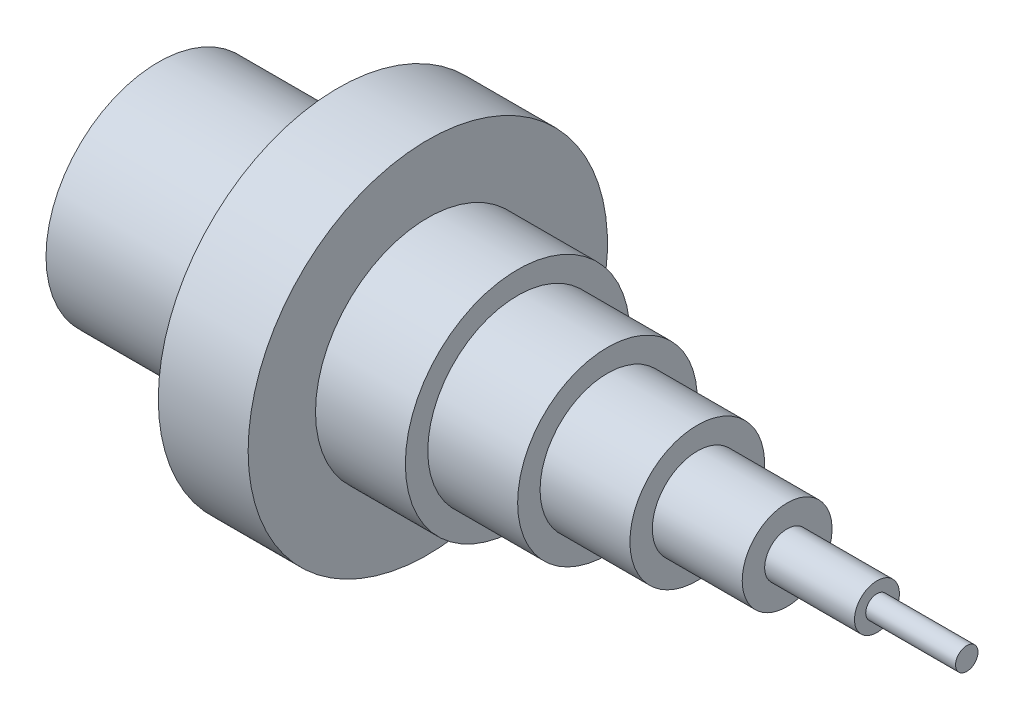
from build123d import *

# Parameters (mm, degrees)
SKETCH3_R          = 508
CUT_EXTRUDE2_DEPTH = 1016


with BuildPart() as part:
    # Sketch1 → Revolve1 (revolve)
    with BuildSketch(Plane.XY, mode=Mode.PRIVATE) as revolve1_sk:
        Polygon((4064, -127), (3556, -127), (3556, -254), (3048, -254), (3048, -381), (2540, -381), (2540, -508), (2032, -508), (2032, -635), (1524, -635), (1524, -1016), (1016, -1016), (1016, -635), (0, -635), (0, 0), (4572, 0), (4572, -63.5), (4064, -63.5), align=None)
    revolve(revolve1_sk.sketch.rotate(Axis((0, 0, 0), (1, 0, 0)), 270), axis=Axis((0, 0, 0), (1, 0, 0)))  # turned: the seam where the file's is

    # Sketch3 → Cut-Extrude2 (cut)
    with BuildSketch(Plane.ZY):
        Circle(SKETCH3_R)
    extrude(amount=-CUT_EXTRUDE2_DEPTH, mode=Mode.SUBTRACT)


solid = part.part
